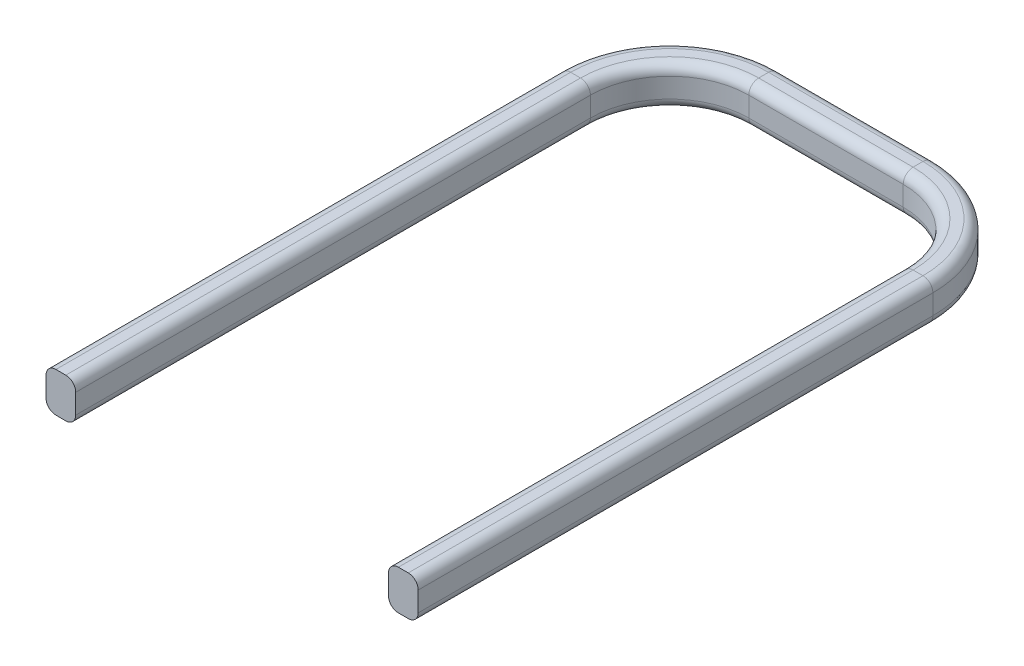
from build123d import *

# Parameters (mm, degrees)
SKETCH2_W = 0.75
SKETCH2_H = 1
FILLET1_R = 0.25


with BuildPart() as part:
    # Sweep1: sweep along a path in Sketch1
    with BuildLine(Plane(origin=(0, 0, 0), x_dir=(1, 0, 0), z_dir=(0, 1, 0))) as sweep1_path:
        Line((-3.95, 0), (-3.95, 13))
        ThreePointArc((-3.95, 13), (-3.364213562, 14.414213562), (-1.95, 15))
        Line((-1.95, 15), (1.95, 15))
        ThreePointArc((1.95, 15), (3.364213562, 14.414213562), (3.95, 13))
        Line((3.95, 13), (3.95, 0))
    # Sketch2 → Sweep1 (sweep)
    with BuildSketch(Plane.XY):
        with Locations((4.325, 0.5)):
            Rectangle(SKETCH2_W, SKETCH2_H)
    sweep(path=sweep1_path.line)

    # Fillet1
    fillet1_edges = [part.edges().sort_by_distance(p)[0] for p in [
        (4.7, 1, -6.5),
        (3.95, 1, -6.5),
        (3.95, 0, -6.5),
        (-4.7, 0, -6.5),
        (-4.7, 1, -6.5),
        (-3.95, 1, -6.5),
        (-3.95, 0, -6.5),
        (-3.894543648, 0, -14.944543648),
        (-3.894543648, 1, -14.944543648),
        (-3.364213562, 1, -14.414213562),
        (-3.364213562, 0, -14.414213562),
        (0, 0, -15.75),
        (0, 1, -15.75),
        (0, 1, -15),
        (0, 0, -15),
        (3.894543648, 0, -14.944543648),
        (3.894543648, 1, -14.944543648),
        (3.364213562, 1, -14.414213562),
        (3.364213562, 0, -14.414213562),
        (4.7, 0, -6.5),
    ]]
    fillet(fillet1_edges, radius=FILLET1_R)


solid = part.part
